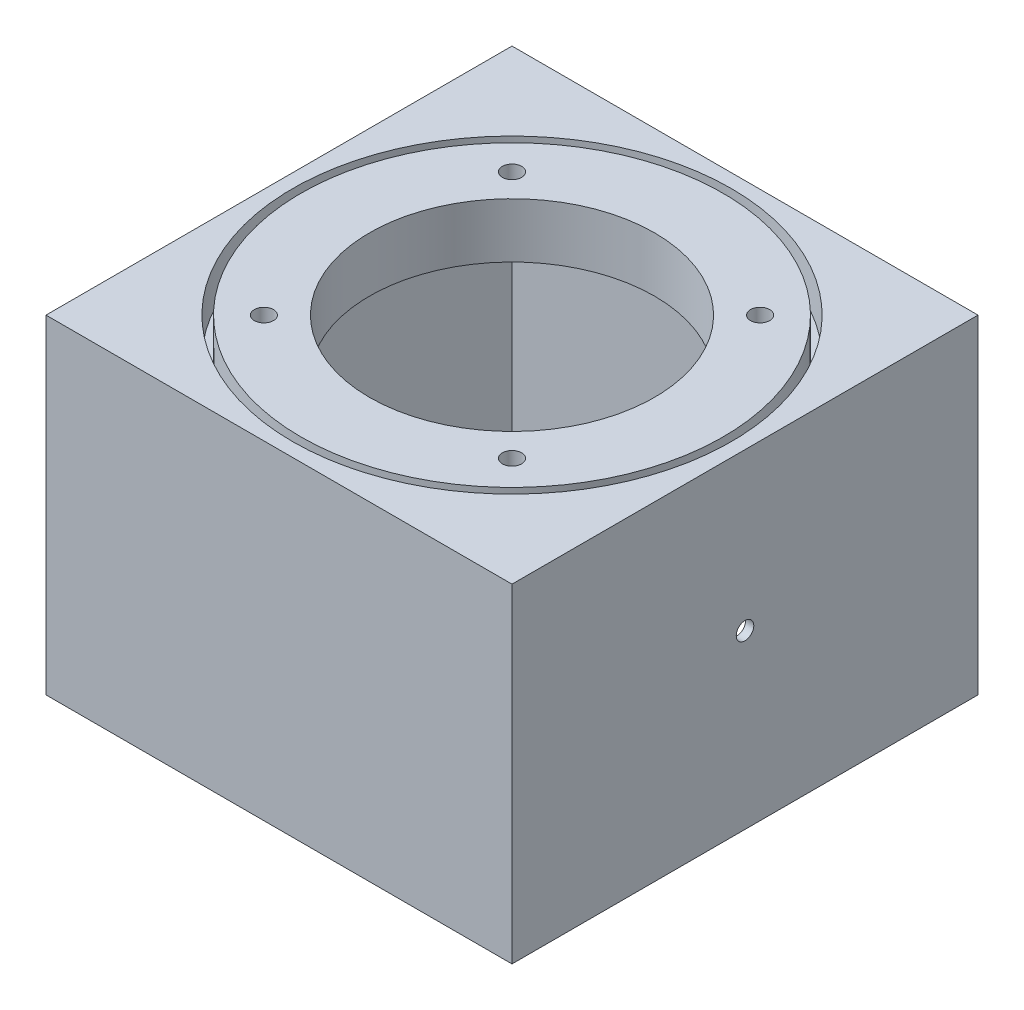
from build123d import *

# Parameters (mm, degrees)
SKETCH1_W           = 85
SKETCH1_H           = 85
SKETCH1_R           = 26
BOSS_EXTRUDE1_DEPTH = 10
SKETCH2_R           = 1.75
CUT_EXTRUDE1_DEPTH  = 11
SKETCH3_W           = 85
SKETCH3_H           = 85
SKETCH3_W_2         = 82
SKETCH3_H_2         = 82
BOSS_EXTRUDE2_DEPTH = 50
SKETCH4_R           = 1.6
CUT_EXTRUDE2_DEPTH  = 86
SKETCH5_R           = 40
SKETCH5_R_2         = 38.5
CUT_EXTRUDE3_DEPTH  = 7


with BuildPart() as part:
    # Sketch1 → Boss-Extrude1 (new body)
    with BuildSketch(Plane(origin=(0, 0, 0), x_dir=(1, 0, 0), z_dir=(0, 1, 0))):
        Rectangle(SKETCH1_W, SKETCH1_H)
        Circle(SKETCH1_R, mode=Mode.SUBTRACT)
    extrude(amount=BOSS_EXTRUDE1_DEPTH)

    # Sketch2 → Cut-Extrude1 (cut, through all)
    with BuildSketch(Plane(origin=(0, 10, 0), x_dir=(1, 0, 0), z_dir=(0, 1, 0))):
        with Locations((22.628070081, 22.628070081)):
            Circle(SKETCH2_R)
        with Locations((-22.626763915, 22.626763915)):
            Circle(SKETCH2_R)
        with Locations((-22.626763915, -22.626763915)):
            Circle(SKETCH2_R)
        with Locations((22.628070081, -22.628070081)):
            Circle(SKETCH2_R)
    extrude(amount=-CUT_EXTRUDE1_DEPTH, mode=Mode.SUBTRACT)

    # Sketch3 → Boss-Extrude2 (add)
    with BuildSketch(Plane(origin=(0, 0, 0), x_dir=(-1, 0, 0), z_dir=(0, -1, 0))):
        Rectangle(SKETCH3_W, SKETCH3_H)
        Rectangle(SKETCH3_W_2, SKETCH3_H_2, mode=Mode.SUBTRACT)
    extrude(amount=BOSS_EXTRUDE2_DEPTH)

    # Sketch4 → Cut-Extrude2 (cut, through all)
    with BuildSketch(Plane.ZY.offset(42.5)):
        with Locations((0, -18.6)):
            Circle(SKETCH4_R)
    extrude(amount=-CUT_EXTRUDE2_DEPTH, mode=Mode.SUBTRACT)

    # Sketch5 → Cut-Extrude3 (cut)
    with BuildSketch(Plane(origin=(0, 10, 0), x_dir=(1, 0, 0), z_dir=(0, 1, 0))):
        Circle(SKETCH5_R)
        Circle(SKETCH5_R_2, mode=Mode.SUBTRACT)
    extrude(amount=-CUT_EXTRUDE3_DEPTH, mode=Mode.SUBTRACT)


solid = part.part
